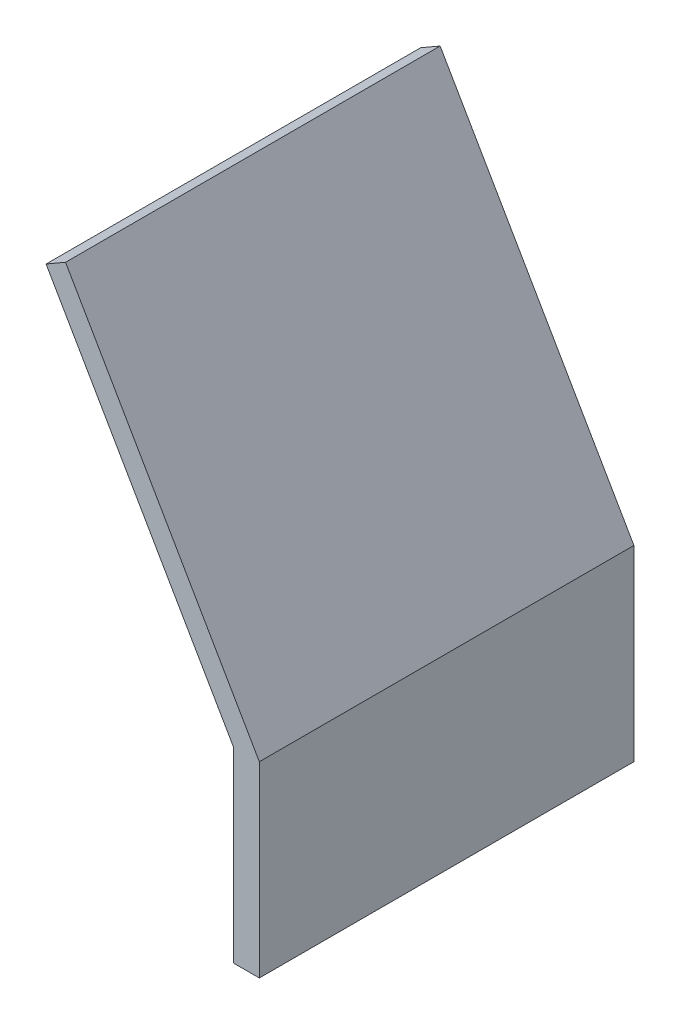
from build123d import *

# Parameters (mm, degrees)
BOSS_EXTRUDE1_DEPTH = 25


with BuildPart() as part:
    # Sketch2 → Boss-Extrude1 (new body, symmetric)
    with BuildSketch(Plane.XY):
        Polygon((-28.464101615, 43.301270189), (-3.464101615, 0), (-3.464101615, -25), (0, -25), (0, 0), (-25.866025404, 44.801270189), align=None)
    extrude(amount=BOSS_EXTRUDE1_DEPTH, both=True)


solid = part.part
